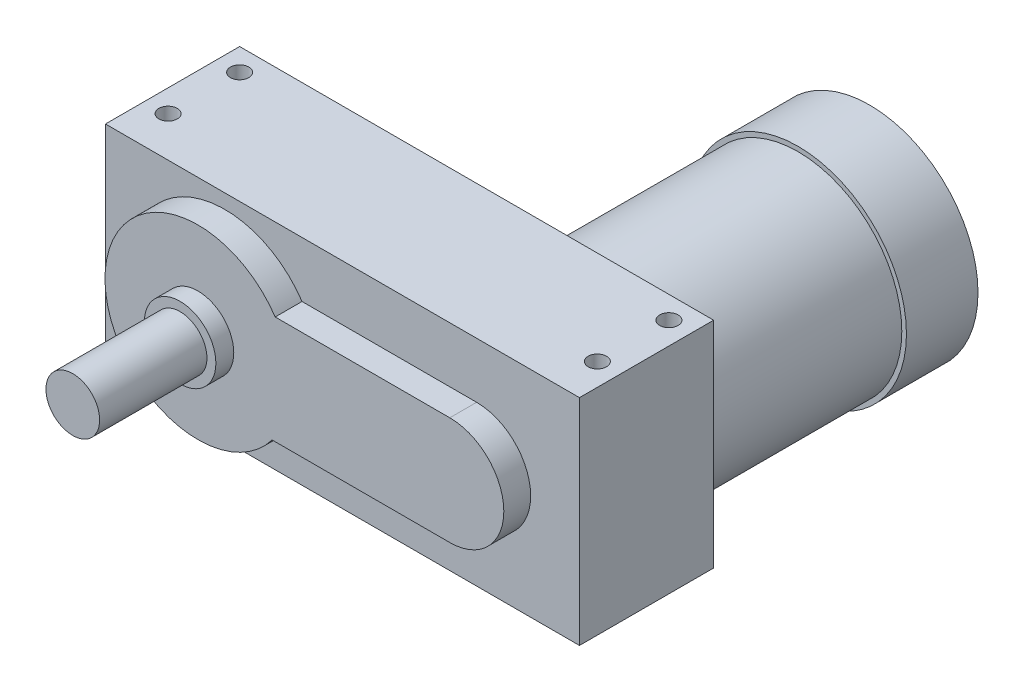
from build123d import *

# Parameters (mm, degrees)
SKETCH1_W                    = 168.275
SKETCH1_H                    = 76.2
EXTRUDE1_DEPTH               = 57.15
SKETCH2_R                    = 12.7
EXTRUDE2_DEPTH               = 6.35
SKETCH3_R                    = 9.525
EXTRUDE3_DEPTH               = 38.1
F_5_16_18_TAPPED_HOLE1_D     = 6.5278
F_5_16_18_TAPPED_HOLE1_DEPTH = 22.9235
F_5_16_18_TAPPED_HOLE1_TIP   = 1.961148974
SKETCH7_R                    = 36.83
EXTRUDE4_DEPTH               = 68.072
SKETCH8_R                    = 38.481
EXTRUDE5_DEPTH               = 25.4
F_5_16_18_TAPPED_HOLE2_D     = 6.5278
F_5_16_18_TAPPED_HOLE2_DEPTH = 22.922992
F_5_16_18_TAPPED_HOLE2_TIP   = 1.961148974
SKETCH11_OUTSIDE_W           = 224.478
SKETCH11_OUTSIDE_H           = 132.784
CUT_EXTRUDE1_DEPTH           = 9.525


with BuildPart() as part:
    # Sketch1 → Extrude1 (new body)
    with BuildSketch(Plane.XY):
        with Locations((41.7703, 0)):
            Rectangle(SKETCH1_W, SKETCH1_H)
    extrude(amount=-EXTRUDE1_DEPTH)

    # Sketch2 → Extrude2 (add)
    with BuildSketch(Plane.XY):
        Circle(SKETCH2_R)
    extrude(amount=EXTRUDE2_DEPTH)

    # Sketch3 → Extrude3 (add)
    with BuildSketch(Plane.XY.offset(6.35)):
        Circle(SKETCH3_R)
    extrude(amount=EXTRUDE3_DEPTH)

    # 5/16-18 Tapped Hole1
    with Locations(Plane.XZ.offset(38.1)):
        with Locations((-34.4297, -23.8125), (-34.4297, -49.2125), (117.9703, -49.2125), (117.9703, -23.8125)):
            Hole(F_5_16_18_TAPPED_HOLE1_D / 2, depth=F_5_16_18_TAPPED_HOLE1_DEPTH)
            with Locations((0, 0, -(F_5_16_18_TAPPED_HOLE1_DEPTH + F_5_16_18_TAPPED_HOLE1_TIP / 2))):  # 118° drill point
                Cone(0, F_5_16_18_TAPPED_HOLE1_D / 2, F_5_16_18_TAPPED_HOLE1_TIP, mode=Mode.SUBTRACT)

    # Sketch7 → Extrude4 (add)
    with BuildSketch(Plane(origin=(0, 0, -57.15), x_dir=(-1, 0, 0), z_dir=(0, 0, -1))):
        with Locations((-87.8078, 0)):
            Circle(SKETCH7_R)
    extrude(amount=EXTRUDE4_DEPTH)

    # Sketch8 → Extrude5 (add)
    with BuildSketch(Plane(origin=(0, 0, -125.222), x_dir=(-1, 0, 0), z_dir=(0, 0, -1))):
        with Locations((-87.8078, 0)):
            Circle(SKETCH8_R)
    extrude(amount=EXTRUDE5_DEPTH)

    # 5/16-18 Tapped Hole2
    with Locations(Plane(origin=(0, 38.1, 0), x_dir=(-1, 0, 0), z_dir=(0, 1, 0))):
        with Locations((34.4297, -23.8125), (34.4297, -49.2125), (-117.9703, -49.2125), (-117.9703, -23.8125)):
            Hole(F_5_16_18_TAPPED_HOLE2_D / 2, depth=F_5_16_18_TAPPED_HOLE2_DEPTH)
            with Locations((0, 0, -(F_5_16_18_TAPPED_HOLE2_DEPTH + F_5_16_18_TAPPED_HOLE2_TIP / 2))):  # 118° drill point
                Cone(0, F_5_16_18_TAPPED_HOLE2_D / 2, F_5_16_18_TAPPED_HOLE2_TIP, mode=Mode.SUBTRACT)

    # Sketch11 outside → Cut-Extrude1 (cut)
    with BuildSketch(Plane.XY):
        with Locations((41.961, 0)):
            Rectangle(SKETCH11_OUTSIDE_W, SKETCH11_OUTSIDE_H)
        with BuildLine():
            Line((89.393090644, 18.410189037), (27.411408932, 18.410189037))
            ThreePointArc((27.411408932, 18.410189037), (-33.006603821, 0.940480831), (26.318636507, -19.941157749))
            Line((26.318636507, -19.941157749), (89.393090644, -19.941157749))
            ThreePointArc((89.393090644, -19.941157749), (108.568764037, -0.765484356), (89.393090644, 18.410189037))
        make_face(mode=Mode.SUBTRACT)
    extrude(amount=-CUT_EXTRUDE1_DEPTH, mode=Mode.SUBTRACT)


solid = part.part
